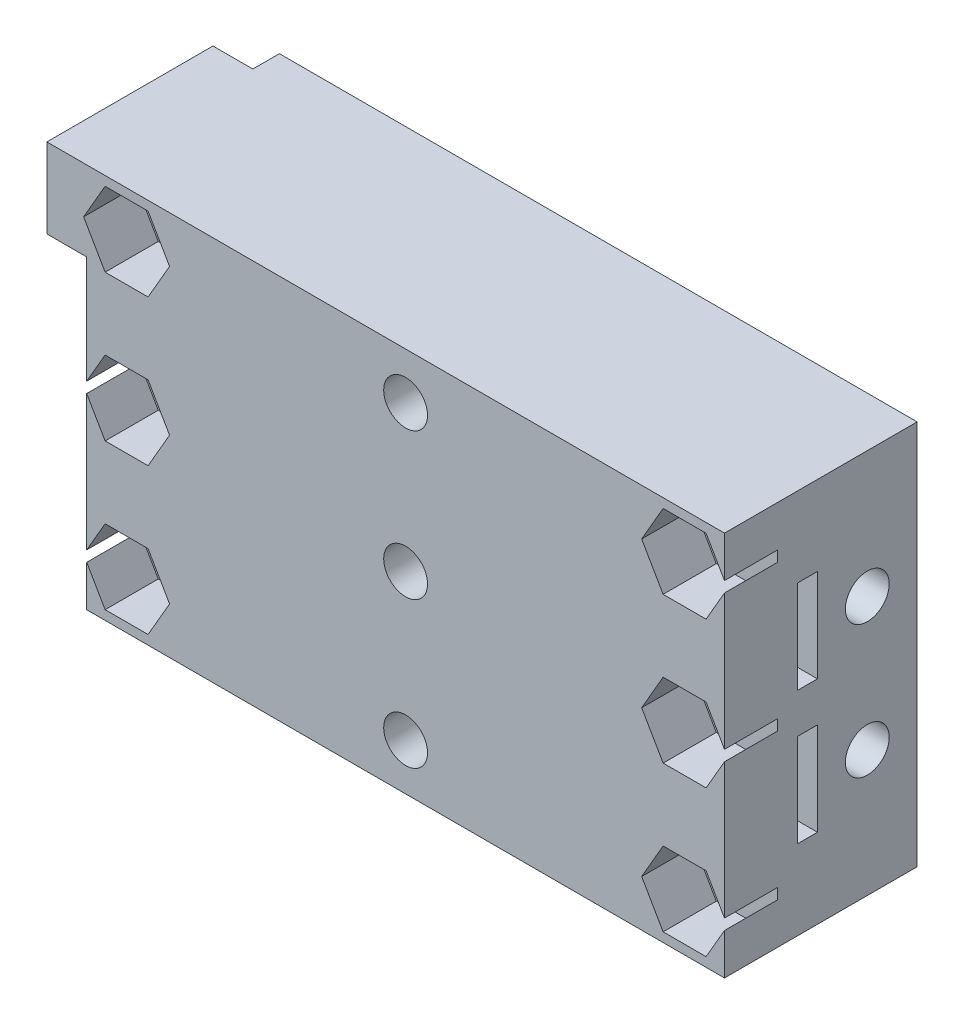
from build123d import *
from build123d.topology import SkipClean

# Parameters (mm, degrees)
ESBO_O1_W                = 48
ESBO_O1_H                = 29
ESBO_O1_R                = 1.65
RESSALTO_EXTRUS_O1_DEPTH = 12
CORTE_EXTRUS_O3_START    = 1.5
ESBO_O2_R                = 0.6
CORTE_EXTRUS_O3_DEPTH    = 7
ESBO_O3_R                = 1.65
CORTE_EXTRUS_O4_DEPTH    = 16
CORTE_EXTRUS_O5_DEPTH    = 2
ESBO_O6_R                = 1.65
CORTE_EXTRUS_O7_DEPTH    = 31.5
ESBO_O7_R                = 3.4
CORTE_EXTRUS_O9_DEPTH    = 3
ESBO_O9_W                = 3
ESBO_O9_H                = 6
RESSALTO_EXTRUS_O2_DEPTH = 10
ESBO_O11_R               = 1.65
RESSALTO_EXTRUS_O3_DEPTH = 2.5
CORTE_EXTRUS_O10_DEPTH   = 4


with BuildPart() as part:
    # Esboço1 → Ressalto-extrusão1 (new body)
    with BuildSketch(Plane.XY):
        Rectangle(ESBO_O1_W, ESBO_O1_H)
        with Locations((-21, 11)):
            Circle(ESBO_O1_R, mode=Mode.SUBTRACT)
        with Locations(Location((-21, -11, 0), (0, 0, 180))):
            Circle(ESBO_O1_R, mode=Mode.SUBTRACT)
        with Locations((21, -11)):
            Circle(ESBO_O1_R, mode=Mode.SUBTRACT)
        with Locations(Location((21, 11, 0), (0, 0, 180))):
            Circle(ESBO_O1_R, mode=Mode.SUBTRACT)
    extrude(amount=RESSALTO_EXTRUS_O1_DEPTH)

    # Esboço2 → Corte-extrusão3 (cut)
    with BuildSketch(Plane(origin=(0, 0, 0), x_dir=(1, 0, 0), z_dir=(0, 1, 0)).offset(CORTE_EXTRUS_O3_START)):
        with Locations((-23, 0)):
            Circle(ESBO_O2_R)
        with Locations((-21, 0)):
            Circle(ESBO_O2_R)
        with Locations((-19, 0)):
            Circle(ESBO_O2_R)
        with Locations((19, 0)):
            Circle(ESBO_O2_R)
        with Locations((21, 0)):
            Circle(ESBO_O2_R)
        with Locations((23, 0)):
            Circle(ESBO_O2_R)
        with BuildLine():
            Line((-24, -9), (-8, -9))
            ThreePointArc((-8, -9), (-4.818019485, -7.681980515), (-3.5, -4.5))
            Line((-3.5, -4.5), (-3.5, 0))
            Line((-3.5, 0), (-18, 0))
            Line((-18, 0), (-18, -7.5))
            Line((-18, -7.5), (-24, -7.5))
            Line((-24, -7.5), (-24, -9))
        make_face()
        with BuildLine():
            Line((24, -7.5), (24, -9))
            Line((24, -9), (8, -9))
            ThreePointArc((8, -9), (4.818019485, -7.681980515), (3.5, -4.5))
            Line((3.5, -4.5), (3.5, 0))
            Line((3.5, 0), (18, 0))
            Line((18, 0), (18, -7.5))
            Line((18, -7.5), (24, -7.5))
        make_face()
    corte_extrus_o3 = extrude(amount=CORTE_EXTRUS_O3_DEPTH, mode=Mode.SUBTRACT)

    # Espelhar1: Corte-extrusão3 across plane
    add(corte_extrus_o3.mirror(Plane.ZX), mode=Mode.SUBTRACT)

    # Esboço3 → Corte-extrusão4 (cut)
    with BuildSketch(Plane(origin=(24, 0, 0), x_dir=(0, 0, -1), z_dir=(1, 0, 0))):
        with Locations((-3.75, 5)):
            Circle(ESBO_O3_R)
        with Locations((-3.75, -5)):
            Circle(ESBO_O3_R)
    corte_extrus_o4 = extrude(amount=-CORTE_EXTRUS_O4_DEPTH, mode=Mode.SUBTRACT)

    # Esboço4 → Corte-extrusão5 (cut)
    with BuildSketch(Plane.ZY.offset(-18)):
        Polygon((6.925426481, 5), (5.33771324, 7.75), (2.16228676, 7.75), (0.574573519, 5), (2.16228676, 2.25), (5.33771324, 2.25), align=None)
        Polygon((6.925426481, -5), (5.33771324, -2.25), (2.16228676, -2.25), (0.574573519, -5), (2.16228676, -7.75), (5.33771324, -7.75), align=None)
    corte_extrus_o5 = extrude(amount=-CORTE_EXTRUS_O5_DEPTH, mode=Mode.SUBTRACT)

    # Esboço6 → Corte-extrusão7 (cut, through all)
    with BuildSketch(Plane(origin=(0, 0, 0), x_dir=(-1, 0, 0), z_dir=(0, 0, -1))):
        with Locations((-21, 0)):
            Circle(ESBO_O6_R)
        with Locations(Location((21, 0, 0), (0, 0, 291.323686263))):
            Circle(ESBO_O6_R)
        Circle(ESBO_O6_R)
        with Locations((0, 11)):
            Circle(ESBO_O6_R)
        with Locations(Location((0, -11, 0), (0, 0, 180))):
            Circle(ESBO_O6_R)
    extrude(amount=-CORTE_EXTRUS_O7_DEPTH, mode=Mode.SUBTRACT)

    # Espelhar2: Corte-extrusão4, Corte-extrusão5 across plane
    add(corte_extrus_o4.mirror(Plane(origin=(0, 0, 0), x_dir=(0, 0, 1), z_dir=(1, 0, 0))), mode=Mode.SUBTRACT)
    add(corte_extrus_o5.mirror(Plane(origin=(0, 0, 0), x_dir=(0, 0, 1), z_dir=(1, 0, 0))), mode=Mode.SUBTRACT)

    # Esboço7 → Corte-extrusão9 (cut)
    with BuildSketch(Plane(origin=(0, 0, 0), x_dir=(-1, 0, 0), z_dir=(0, 0, -1))):
        with Locations((0, 11)):
            Circle(ESBO_O7_R)
        Circle(ESBO_O7_R)
        with Locations((0, -11)):
            Circle(ESBO_O7_R)
    extrude(amount=-CORTE_EXTRUS_O9_DEPTH, mode=Mode.SUBTRACT)

    # Esboço9 → Ressalto-extrusão2 (add)
    with BuildSketch(Plane.XY.offset(12)):
        with Locations((-25.5, 11.5)):
            Rectangle(ESBO_O9_W, ESBO_O9_H)
    extrude(amount=-RESSALTO_EXTRUS_O2_DEPTH)

    # Esboço11 → Ressalto-extrusão3 (add)
    with SkipClean():  # the faces are left unmerged after this step: merging them gives an invalid solid
        with BuildSketch(Plane.XY.offset(12)):
            Polygon((24, -14.5), (24, 14.5), (-27, 14.5), (-27, 8.5), (-24, 8.5), (-24, -14.5), align=None)
            with Locations(Location((-21, -11, 0), (0, 0, 180))):
                Circle(ESBO_O11_R, mode=Mode.SUBTRACT)
            with Locations(Location((0, -11, 0), (0, 0, 180))):
                Circle(ESBO_O11_R, mode=Mode.SUBTRACT)
            with Locations((21, -11)):
                Circle(ESBO_O11_R, mode=Mode.SUBTRACT)
            with Locations(Location((21, 0, 0), (0, 0, 248.676313737))):
                Circle(ESBO_O11_R, mode=Mode.SUBTRACT)
            with Locations(Location((21, 11, 0), (0, 0, 180))):
                Circle(ESBO_O11_R, mode=Mode.SUBTRACT)
            with Locations(Location((0, 0, 0), (0, 0, 180))):
                Circle(ESBO_O11_R, mode=Mode.SUBTRACT)
            with Locations(Location((0, 11, 0), (0, 0, 180))):
                Circle(ESBO_O11_R, mode=Mode.SUBTRACT)
            with Locations(Location((-21, 0, 0), (0, 0, 248.676313737))):
                Circle(ESBO_O11_R, mode=Mode.SUBTRACT)
            with Locations((-21, 11)):
                Circle(ESBO_O11_R, mode=Mode.SUBTRACT)
        extrude(amount=RESSALTO_EXTRUS_O3_DEPTH)

    # Esboço8 → Corte-extrusão10 (cut)
    with SkipClean():  # the faces are left unmerged after this step: merging them gives an invalid solid
        with BuildSketch(Plane.XY.offset(14.5)):
            Polygon((24.233161507, 11), (22.616580754, 13.8), (19.383419246, 13.8), (17.766838493, 11), (19.383419246, 8.2), (22.616580754, 8.2), align=None)
            Polygon((-22.616580754, 8.2), (-24.233161507, 11), (-22.616580754, 13.8), (-19.383419246, 13.8), (-17.766838493, 11), (-19.383419246, 8.2), align=None)
            Polygon((-24.233161507, -11), (-22.616580754, -13.8), (-19.383419246, -13.8), (-17.766838493, -11), (-19.383419246, -8.2), (-22.616580754, -8.2), align=None)
            Polygon((22.616580754, -8.2), (24.233161507, -11), (22.616580754, -13.8), (19.383419246, -13.8), (17.766838493, -11), (19.383419246, -8.2), align=None)
            Polygon((-22.616580754, -2.8), (-24.233161507, 0), (-22.616580754, 2.8), (-19.383419246, 2.8), (-17.766838493, 0), (-19.383419246, -2.8), align=None)
            Polygon((24.233161507, 0), (22.616580754, 2.8), (19.383419246, 2.8), (17.766838493, 0), (19.383419246, -2.8), (22.616580754, -2.8), align=None)
        extrude(amount=-CORTE_EXTRUS_O10_DEPTH, mode=Mode.SUBTRACT)


solid = part.part
